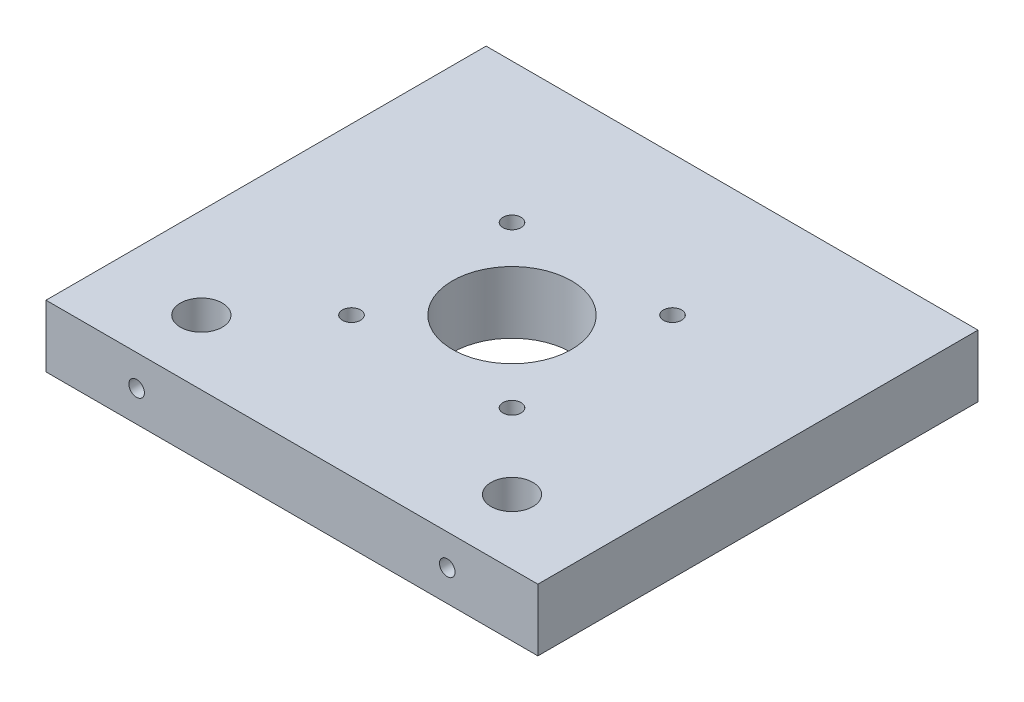
from build123d import *

# Parameters (mm, degrees)
SKETCH1_W           = 95
SKETCH1_H           = 12
BOSS_EXTRUDE1_DEPTH = 85
SKETCH2_R           = 4.05
SKETCH2_R_2         = 11.5
CUT_EXTRUDE1_DEPTH  = 13
CUT_EXTRUDE3_REACH  = 87
SKETCH4_R           = 1.5
SKETCH6_R           = 1.75
CUT_EXTRUDE4_DEPTH  = 13.0000001


with BuildPart() as part:
    # Sketch1 → Boss-Extrude1 (new body)
    with BuildSketch(Plane.XY):
        Rectangle(SKETCH1_W, SKETCH1_H)
    extrude(amount=BOSS_EXTRUDE1_DEPTH)

    # Sketch2 → Cut-Extrude1 (cut, through all)
    with BuildSketch(Plane.XZ.offset(6)):
        with Locations(Location((-30, 72.5, 0), (0, 0, 270))):  # turned: the seam where the file's is
            Circle(SKETCH2_R)
        with Locations(Location((30, 72.5, 0), (0, 0, 270))):  # turned: the seam where the file's is
            Circle(SKETCH2_R)
        with Locations(Location((0, 42.5, 0), (0, 0, 270))):  # turned: the seam where the file's is
            Circle(SKETCH2_R_2)
    extrude(amount=-CUT_EXTRUDE1_DEPTH, mode=Mode.SUBTRACT)

    # Sketch4 → Cut-Extrude3 (cut, up to next)
    with BuildSketch(Plane.XY.offset(85), mode=Mode.PRIVATE) as cut_extrude3_sk1:
        with Locations((30, 0)):
            Circle(SKETCH4_R)
    cut_extrude3_tool1 = extrude(cut_extrude3_sk1.sketch, amount=-CUT_EXTRUDE3_REACH, mode=Mode.PRIVATE) & part.part
    add(cut_extrude3_tool1.solids().sort_by_distance((30, 0, 85))[0], mode=Mode.SUBTRACT)
    # Sketch4 → Cut-Extrude3 (cut, up to next)
    with BuildSketch(Plane.XY.offset(85), mode=Mode.PRIVATE) as cut_extrude3_sk2:
        with Locations((-30, 0)):
            Circle(SKETCH4_R)
    cut_extrude3_tool2 = extrude(cut_extrude3_sk2.sketch, amount=-CUT_EXTRUDE3_REACH, mode=Mode.PRIVATE) & part.part
    add(cut_extrude3_tool2.solids().sort_by_distance((-30, 0, 85))[0], mode=Mode.SUBTRACT)

    # Sketch6 → Cut-Extrude4 (cut, through all)
    with BuildSketch(Plane.XZ.offset(6)):
        with Locations(Location((-15.5, 58, 0), (0, 0, 270))):  # turned: the seam where the file's is
            Circle(SKETCH6_R)
        with Locations(Location((-15.5, 27, 0), (0, 0, 270))):  # turned: the seam where the file's is
            Circle(SKETCH6_R)
        with Locations(Location((15.5, 58, 0), (0, 0, 270))):  # turned: the seam where the file's is
            Circle(SKETCH6_R)
        with Locations(Location((15.5, 27, 0), (0, 0, 270))):  # turned: the seam where the file's is
            Circle(SKETCH6_R)
    extrude(amount=-CUT_EXTRUDE4_DEPTH, mode=Mode.SUBTRACT)


solid = part.part
